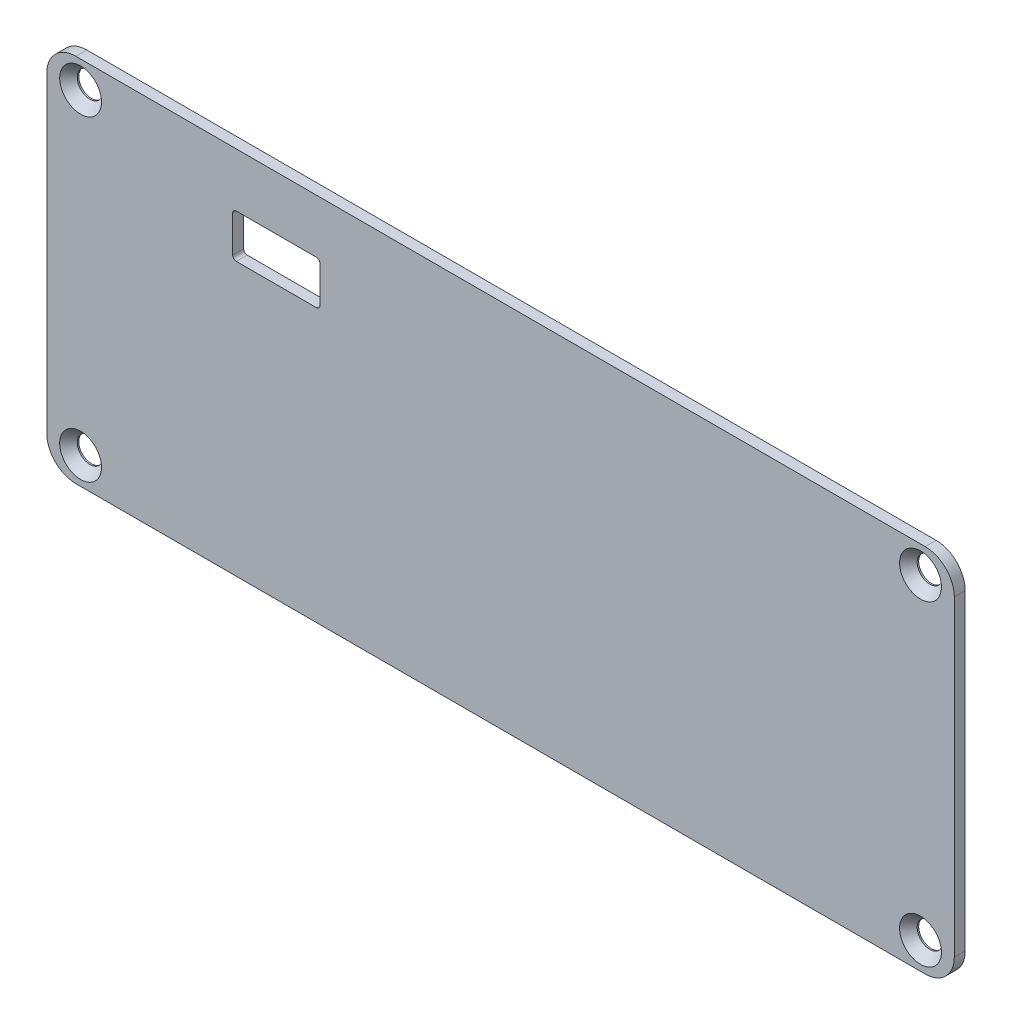
from build123d import *

# Parameters (mm, degrees)
SKETCH1_W                                      = 124.8
SKETCH1_H                                      = 50.9
SKETCH1_W_2                                    = 12
SKETCH1_H_2                                    = 6
BOSS_EXTRUDE1_DEPTH                            = 1.5
CSK_FOR_M3_5_FLAT_HEAD_MACHINE_SCREW1_AT_COUNT = 2
CSK_FOR_M3_5_FLAT_HEAD_MACHINE_SCREW1_AT_PITCH = 115.5
CSK_FOR_M3_5_FLAT_HEAD_MACHINE_SCREW_2_COUNT   = 2
CSK_FOR_M3_5_FLAT_HEAD_MACHINE_SCREW_2_PITCH   = 123.420014584
CSK_FOR_M3_5_FLAT_HEAD_MACHINE_SCREW_3_COUNT   = 2
CSK_FOR_M3_5_FLAT_HEAD_MACHINE_SCREW_3_PITCH   = 43.5
FILLET2_R                                      = 4
FILLET3_R                                      = 0.5


with BuildPart() as part:
    # Sketch1 → Boss-Extrude1 (new body)
    with BuildSketch(Plane.XY):
        with Locations((62.4, -25.45)):
            Rectangle(SKETCH1_W, SKETCH1_H)
        with Locations((31.565, -10.4)):
            Rectangle(SKETCH1_W_2, SKETCH1_H_2, mode=Mode.SUBTRACT)
    extrude(amount=BOSS_EXTRUDE1_DEPTH)

    # Sketch2 → CSK for M3.5 Flat Head Machine Screw1 (revolve, cut)
    with BuildSketch(Plane(origin=(4.65, -3.7, 1.5), x_dir=(0, -1, 0), z_dir=(1, 0, 0))):
        Polygon((0, 0), (0, 1.5), (1.75, 1.5), (1.75, 1.294164458), (2.875, 0), align=None)
    csk_for_m3_5_flat_head_machine_screw1 = revolve(axis=Axis((4.65, -3.7, 7.85), (0, 0, -1)), mode=Mode.SUBTRACT)

    # CSK for M3.5 Flat Head Machine Screw1 at: CSK for M3.5 Flat Head Machine Screw1 ×2
    with Locations(*[(i * CSK_FOR_M3_5_FLAT_HEAD_MACHINE_SCREW1_AT_PITCH, 0, 0) for i in range(1, CSK_FOR_M3_5_FLAT_HEAD_MACHINE_SCREW1_AT_COUNT)]):
        add(csk_for_m3_5_flat_head_machine_screw1, mode=Mode.SUBTRACT)

    # CSK for M3.5 Flat Head Machine Screw 2: CSK for M3.5 Flat Head Machine Screw1 ×2
    with Locations(*[Vector(0.935828766, -0.35245499, 0) * (i * CSK_FOR_M3_5_FLAT_HEAD_MACHINE_SCREW_2_PITCH) for i in range(1, CSK_FOR_M3_5_FLAT_HEAD_MACHINE_SCREW_2_COUNT)]):
        add(csk_for_m3_5_flat_head_machine_screw1, mode=Mode.SUBTRACT)

    # CSK for M3.5 Flat Head Machine Screw 3: CSK for M3.5 Flat Head Machine Screw1 ×2
    with Locations(*[(0, -i * CSK_FOR_M3_5_FLAT_HEAD_MACHINE_SCREW_3_PITCH, 0) for i in range(1, CSK_FOR_M3_5_FLAT_HEAD_MACHINE_SCREW_3_COUNT)]):
        add(csk_for_m3_5_flat_head_machine_screw1, mode=Mode.SUBTRACT)

    # Fillet2
    fillet2_edges = [part.edges().sort_by_distance(p)[0] for p in [
        (124.8, -50.9, 0.75),
        (0, -50.9, 0.75),
        (0, 0, 0.75),
        (124.8, 0, 0.75),
    ]]
    fillet(fillet2_edges, radius=FILLET2_R)

    # Fillet3
    fillet3_edges = [part.edges().sort_by_distance(p)[0] for p in [
        (25.565, -7.4, 0.75),
        (25.565, -13.4, 0.75),
        (37.565, -13.4, 0.75),
        (37.565, -7.4, 0.75),
    ]]
    fillet(fillet3_edges, radius=FILLET3_R)


solid = part.part
